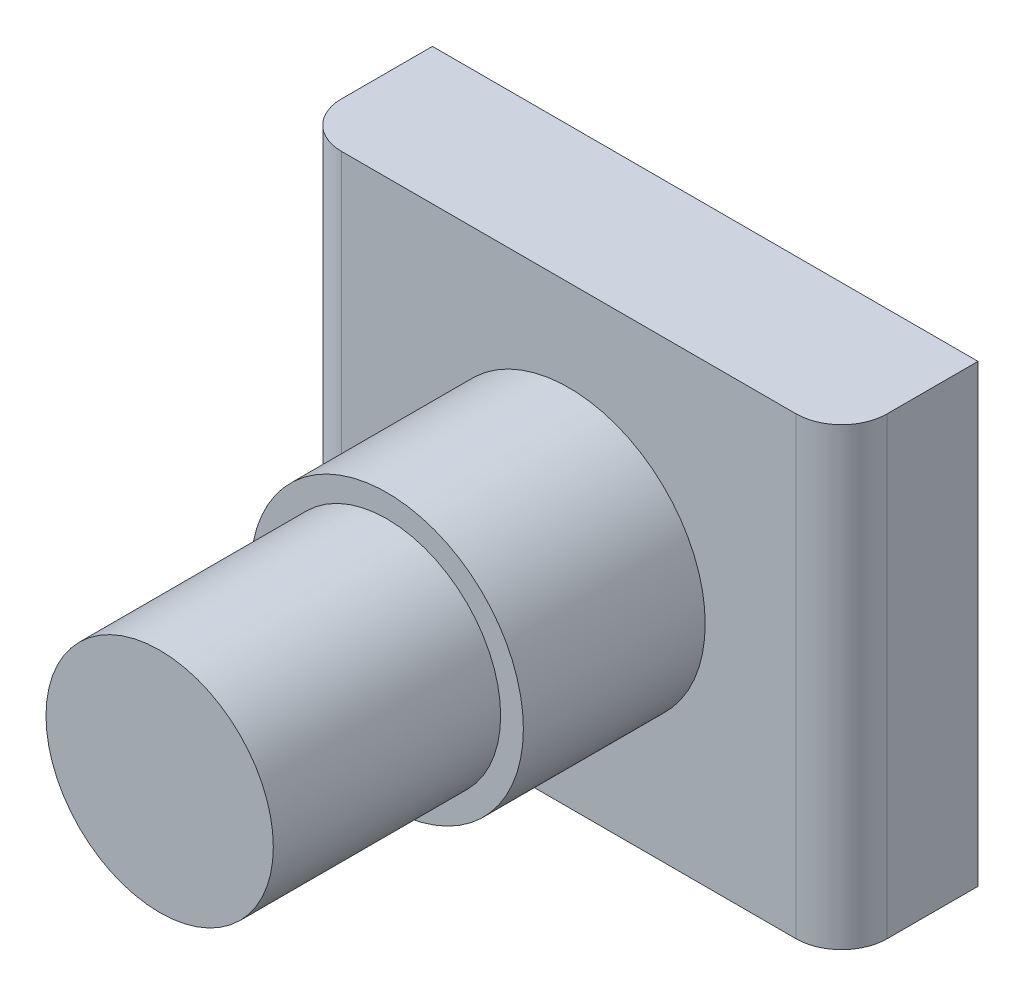
from build123d import *

# Parameters (mm, degrees)
SKETCH2_W           = 12
SKETCH2_H           = 10
BOSS_EXTRUDE1_DEPTH = 3
FILLET1_R           = 1


with BuildPart() as part:
    # Sketch2 → Boss-Extrude1 (new body)
    with BuildSketch(Plane.XY):
        Rectangle(SKETCH2_W, SKETCH2_H)
    extrude(amount=BOSS_EXTRUDE1_DEPTH)

    # Sketch3 → Revolve1 (revolve)
    with BuildSketch(Plane(origin=(0, 0, 0), x_dir=(0, 0, -1), z_dir=(1, 0, 0))):
        Polygon((-3, 0), (-3, 3), (-7, 3), (-7, 2.5), (-12, 2.5), (-12, 0), align=None)
    revolve(axis=Axis((0, 0, 12), (0, 0, -1)))

    # Fillet1
    fillet1_edges = [part.edges().sort_by_distance(p)[0] for p in [
        (-6, 0, 3),
        (6, 0, 3),
    ]]
    fillet(fillet1_edges, radius=FILLET1_R)


solid = part.part
